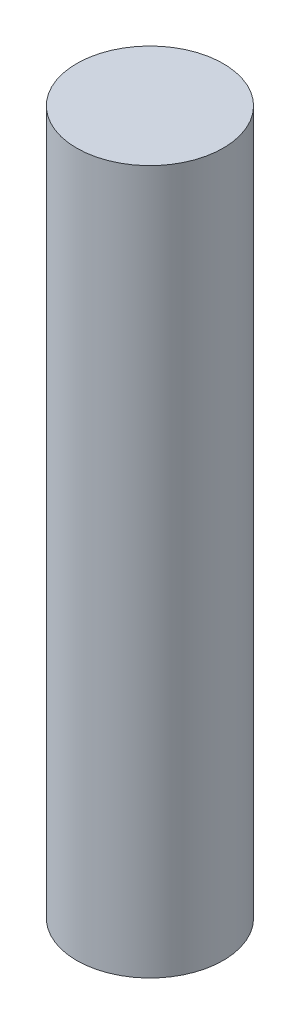
from build123d import *

# Parameters (mm, degrees)
SKETCH1_R           = 7.9375
BOSS_EXTRUDE1_DEPTH = 76.2


with BuildPart() as part:
    # Sketch1 → Boss-Extrude1 (new body)
    with BuildSketch(Plane(origin=(0, 0, 0), x_dir=(1, 0, 0), z_dir=(0, 1, 0))):
        Circle(SKETCH1_R)
    extrude(amount=BOSS_EXTRUDE1_DEPTH)


solid = part.part
